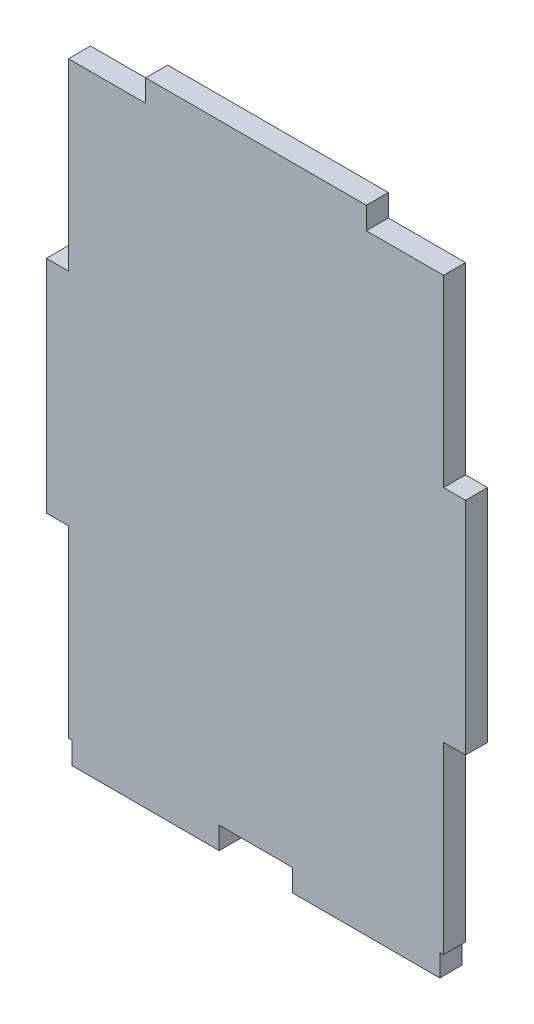
from build123d import *

# Parameters (mm, degrees)
BOSS_EXTRUDE1_DEPTH = 1.5


with BuildPart() as part:
    # Sketch1 → Boss-Extrude1 (new body, symmetric)
    with BuildSketch(Plane.XY):
        Polygon((15, 40), (25.5, 40), (25.5, 15), (28.5, 15), (28.5, -15), (25.5, -15), (25.5, -40), (25, -40), (25, -43), (5, -43), (5, -40), (-5, -40), (-5, -43), (-25, -43), (-25, -40), (-25.5, -40), (-25.5, -15), (-28.5, -15), (-28.5, 15), (-25.5, 15), (-25.5, 40), (-15, 40), (-15, 43), (15, 43), align=None)
    extrude(amount=BOSS_EXTRUDE1_DEPTH, both=True)


solid = part.part
